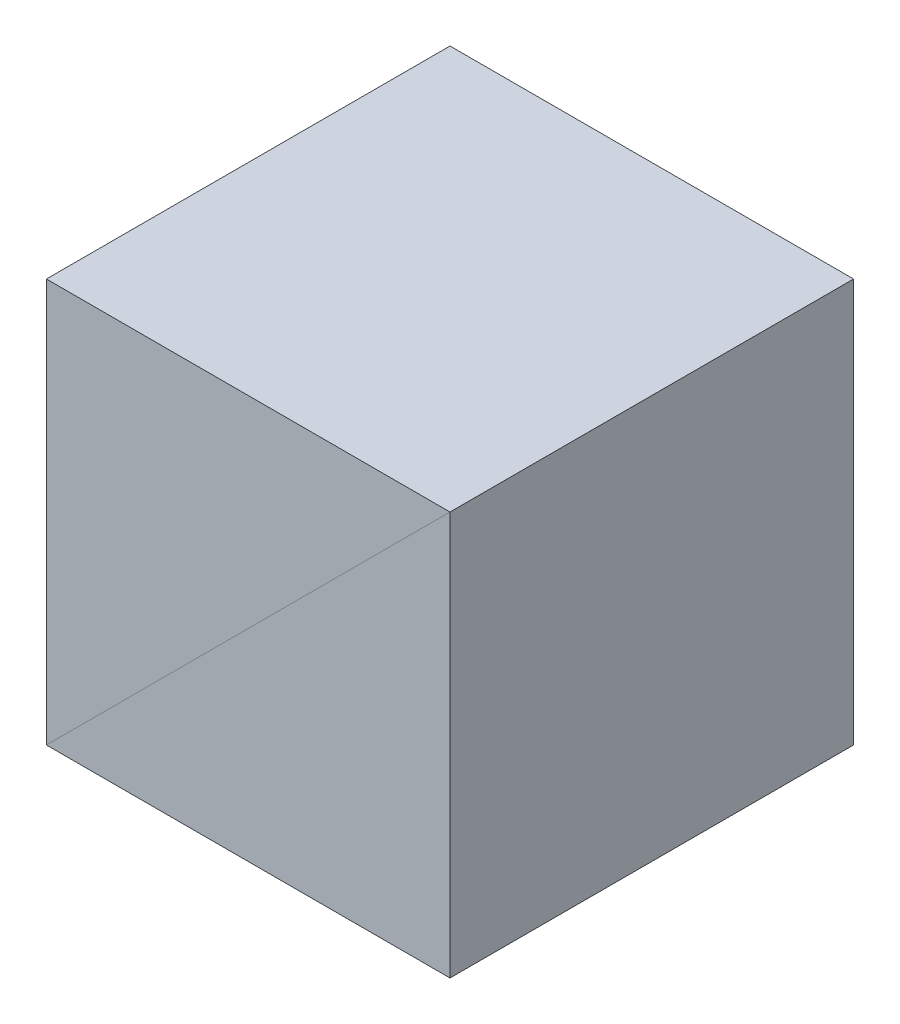
from build123d import *

# Parameters (mm, degrees)
EXTRUDE_1_DEPTH = 2.5


with BuildPart() as part:
    # 草图1 → 凸台-拉伸1 (new body, symmetric)
    with BuildSketch(Plane.XY):
        Polygon((-2.5, -2.5), (2.5, -2.5), (2.5, 2.5), align=None)
    extrude(amount=EXTRUDE_1_DEPTH, both=True)


with BuildPart() as body_2:
    # 镜向2: mirrored copy
    add(part.part.mirror(Plane(origin=(2.5, 2.5, 2.5), x_dir=(0, 0, 1), z_dir=(0.707106781, -0.707106781, 0))))


solid = Compound([part.part, body_2.part])
